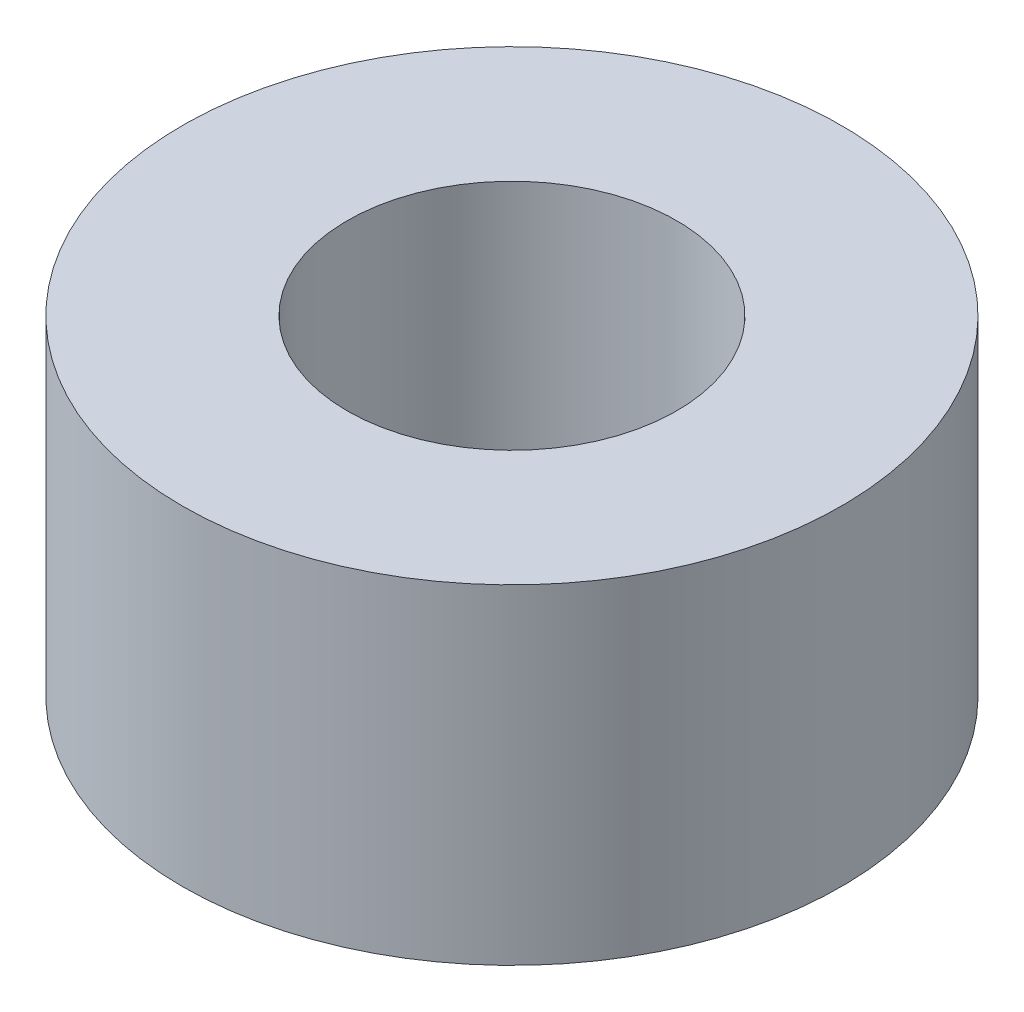
from build123d import *

# Parameters (mm, degrees)
SKETCH1_R           = 3
BOSS_EXTRUDE1_DEPTH = 3
SKETCH2_R           = 1.5
CUT_EXTRUDE1_DEPTH  = 3


with BuildPart() as part:
    # Sketch1 → Boss-Extrude1 (new body)
    with BuildSketch(Plane(origin=(0, 0, 0), x_dir=(1, 0, 0), z_dir=(0, 1, 0))):
        with Locations(Location((0, 0, 0), (0, 0, 270))):  # turned: the seam where the file's is
            Circle(SKETCH1_R)
    extrude(amount=BOSS_EXTRUDE1_DEPTH)

    # Sketch2 → Cut-Extrude1 (cut)
    with BuildSketch(Plane(origin=(0, 3, 0), x_dir=(1, 0, 0), z_dir=(0, 1, 0))):
        with Locations(Location((0, 0, 0), (0, 0, 270))):  # turned: the seam where the file's is
            Circle(SKETCH2_R)
    extrude(amount=-CUT_EXTRUDE1_DEPTH, mode=Mode.SUBTRACT)


solid = part.part
